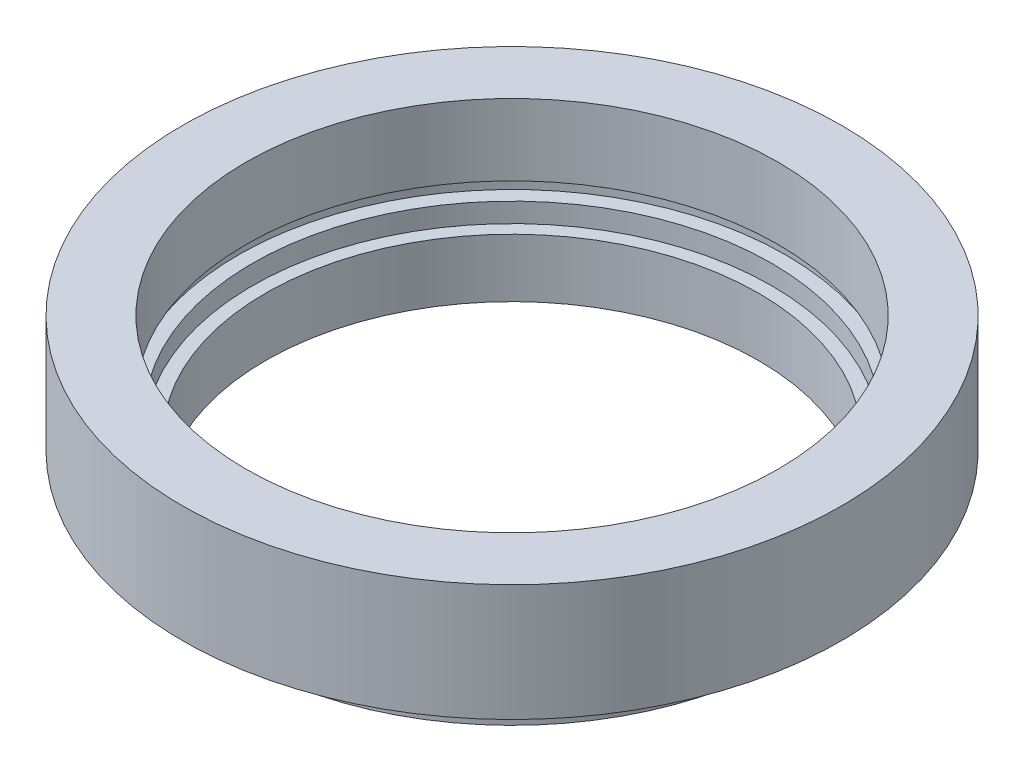
from build123d import *


with BuildPart() as part:
    # 草图1 → 旋转1 (revolve)
    with BuildSketch(Plane.XY, mode=Mode.PRIVATE) as revolve_1_sk:
        Polygon((19, 0), (21, 0), (21, 2.5), (20.5, 2.5), (20.5, 3.5), (25.4, 3.5), (25.4, 12.5), (20.5, 12.5), (20.5, 7), (21.1, 7), (21.1, 6), (20, 6), (20, 4.5), (19, 4.5), align=None)
    revolve(revolve_1_sk.sketch.rotate(Axis((0, 0, 0), (0, 1, 0)), 90), axis=Axis((0, 0, 0), (0, 1, 0)))  # turned: the seam where the file's is


solid = part.part
